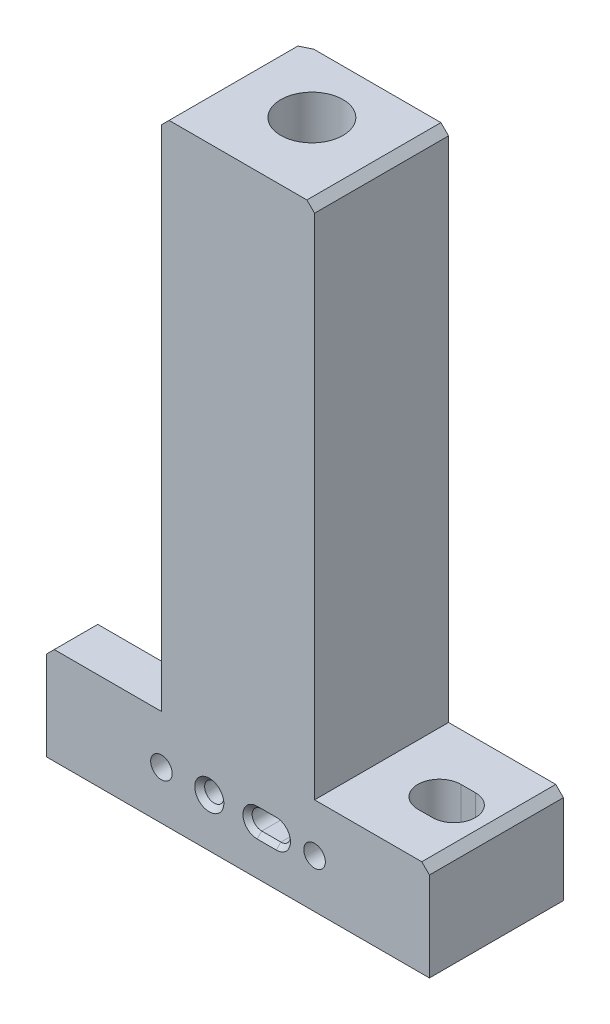
from build123d import *

# Parameters (mm, degrees)
EXTRUDE1_DEPTH                                   = 44.45
CHAMFER1_SIZE                                    = 2.54
CHAMFER2_SIZE                                    = 2.54
F_13_16_0_8125_DIAMETER_HOLE1_D                  = 20.6375
F_13_16_0_8125_DIAMETER_HOLE1_DEPTH              = 63.754
F_60_0_04_DIAMETER_HOLE1_REACH                   = 46.45
F_60_0_04_DIAMETER_HOLE1_BORE_R                  = 0.508
CBORE_FOR_1_4_SOCKET_HEAD_CAP_SCREW1_D           = 7.14248
CBORE_FOR_1_4_SOCKET_HEAD_CAP_SCREW1_CBORE_D     = 11.1125
CBORE_FOR_1_4_SOCKET_HEAD_CAP_SCREW1_CBORE_DEPTH = 15.748
F_1_4_0_25_DIAMETER_HOLE2_D                      = 6.36778
F_1_4_0_25_DIAMETER_HOLE2_DEPTH                  = 12.7
F_1_4_0_25_DIAMETER_HOLE2_CSINK_D                = 9.652
F_1_4_0_25_DIAMETER_HOLE2_CSINK_ANGLE            = 90
F_1_4_0_25_DIAMETER_HOLE2_TIP                    = 1.913074116
EXTRUDE4_DEPTH                                   = 12.7
F_1_2_20_TAPPED_HOLE3_D                          = 11.50874
F_1_2_20_TAPPED_HOLE3_DEPTH                      = 82.55
F_1_2_20_TAPPED_HOLE3_TIP                        = 3.322287069
EXTRUDE5_DEPTH                                   = 172.0690001
EXTRUDE5_DEPTH_BACK                              = 33.02
CHAMFER3_SIZE                                    = 1.524
EXTRUDE6_DEPTH                                   = 33.131
CUT_EXTRUDE1_DEPTH                               = 33.131


with BuildPart() as part:
    # Sketch1 → Extrude1 (new body)
    with BuildSketch(Plane.XY):
        Polygon((-63.5, 19.16234013), (-25.4, 19.16234013), (-25.4, 190.23134013), (0, 190.23134013), (0, -12.96865987), (-63.5, -12.96865987), align=None)
    extrude1 = extrude(amount=EXTRUDE1_DEPTH)

    # Mirror2: Extrude1 across plane
    add(extrude1.mirror(Plane(origin=(0, -12.96865987, 44.45), x_dir=(0, 0, 1), z_dir=(-1, 0, 0))))

    # Chamfer1
    chamfer1_edges = [part.edges().sort_by_distance(p)[0] for p in [
        (63.5, 19.16234013, 22.225),
        (25.4, 190.23134013, 22.225),
    ]]
    chamfer(chamfer1_edges, length=CHAMFER1_SIZE)

    # Chamfer2
    chamfer2_edges = [part.edges().sort_by_distance(p)[0] for p in [
        (-63.5, 19.16234013, 22.225),
        (-25.4, 190.23134013, 22.225),
    ]]
    chamfer(chamfer2_edges, length=CHAMFER2_SIZE)

    # 13/16 (0.8125) Diameter Hole1
    with Locations(Plane(origin=(0, 190.23134013, 19.939), x_dir=(0, 0, 1), z_dir=(0, 1, 0))):
        with Locations((0, 0)):
            Hole(F_13_16_0_8125_DIAMETER_HOLE1_D / 2, depth=F_13_16_0_8125_DIAMETER_HOLE1_DEPTH)

    # #60 (0.04) Diameter Hole1 bore → #60 (0.04) Diameter Hole1 (cut, up to next)
    with BuildSketch(Plane(origin=(0, 0, 0), x_dir=(-1, 0, 0), z_dir=(0, 0, -1)), mode=Mode.PRIVATE) as f_60_0_04_diameter_hole1_sk1:
        with Locations((0, 129.27134013)):
            Circle(F_60_0_04_DIAMETER_HOLE1_BORE_R)
    f_60_0_04_diameter_hole1_tool1 = extrude(f_60_0_04_diameter_hole1_sk1.sketch, amount=-F_60_0_04_DIAMETER_HOLE1_REACH, mode=Mode.PRIVATE) & part.part
    add(f_60_0_04_diameter_hole1_tool1.solids().sort_by_distance((0, 129.27134, 0))[0], mode=Mode.SUBTRACT)

    # CBORE for 1/4 Socket Head Cap Screw1 (through all)
    with Locations(Plane(origin=(25.4, 3.09684013, 0), x_dir=(-1, 0, 0), z_dir=(0, 0, -1))):
        with Locations((0, 0), (50.8, 0)):
            CounterBoreHole(CBORE_FOR_1_4_SOCKET_HEAD_CAP_SCREW1_D / 2, CBORE_FOR_1_4_SOCKET_HEAD_CAP_SCREW1_CBORE_D / 2, CBORE_FOR_1_4_SOCKET_HEAD_CAP_SCREW1_CBORE_DEPTH)

    # 1/4 (0.25) Diameter Hole2
    with Locations(Plane.XY.offset(44.45)):
        with Locations((-9.525, 3.09684013)):
            CounterSinkHole(F_1_4_0_25_DIAMETER_HOLE2_D / 2, F_1_4_0_25_DIAMETER_HOLE2_CSINK_D / 2, depth=F_1_4_0_25_DIAMETER_HOLE2_DEPTH, counter_sink_angle=F_1_4_0_25_DIAMETER_HOLE2_CSINK_ANGLE)
            with Locations((0, 0, -(F_1_4_0_25_DIAMETER_HOLE2_DEPTH + F_1_4_0_25_DIAMETER_HOLE2_TIP / 2))):  # 118° drill point
                Cone(0, F_1_4_0_25_DIAMETER_HOLE2_D / 2, F_1_4_0_25_DIAMETER_HOLE2_TIP, mode=Mode.SUBTRACT)

    # Sketch22 → Extrude4 (cut)
    with BuildSketch(Plane.XY.offset(44.45)):
        with BuildLine():
            Line((12.7, -0.08704987), (6.35, -0.08704987))
            ThreePointArc((6.35, -0.08704987), (3.16611, 3.09684013), (6.35, 6.28073013))
            Line((6.35, 6.28073013), (12.7, 6.28073013))
            ThreePointArc((12.7, 6.28073013), (15.88389, 3.09684013), (12.7, -0.08704987))
        make_face()
    extrude(amount=-EXTRUDE4_DEPTH, mode=Mode.SUBTRACT)

    # 1/2-20 Tapped Hole3
    with Locations(Plane(origin=(0, 126.47734013, 0), x_dir=(-1, 0, 0), z_dir=(0, 1, 0))):
        with Locations((0, 19.939)):
            Hole(F_1_2_20_TAPPED_HOLE3_D / 2, depth=F_1_2_20_TAPPED_HOLE3_DEPTH)
            with Locations((0, 0, -(F_1_2_20_TAPPED_HOLE3_DEPTH + F_1_2_20_TAPPED_HOLE3_TIP / 2))):  # 120° drill point
                Cone(0, F_1_2_20_TAPPED_HOLE3_D / 2, F_1_2_20_TAPPED_HOLE3_TIP, mode=Mode.SUBTRACT)

    # Sketch27 → Extrude5 (cut, two sides)
    with BuildSketch(Plane(origin=(0, 19.16234013, 0), x_dir=(1, 0, 0), z_dir=(0, 1, 0))) as extrude5_sk:
        Polygon((-19.338095495, 0), (-63.5, -21.5392), (-63.5, 0), align=None)
    extrude(amount=EXTRUDE5_DEPTH, mode=Mode.SUBTRACT)
    extrude(extrude5_sk.sketch, amount=-EXTRUDE5_DEPTH_BACK, mode=Mode.SUBTRACT)

    # Chamfer3
    chamfer3_edges = [part.edges().sort_by_distance(p)[0] for p in [
        (15.88389, 3.09684013, 44.45),
        (9.525, 6.28073013, 44.45),
        (3.16611, 3.09684013, 44.45),
        (9.525, -0.08704987, 44.45),
    ]]
    chamfer(chamfer3_edges, length=CHAMFER3_SIZE)

    # Sketch28 → Extrude6 (cut, through all)
    with BuildSketch(Plane(origin=(0, 19.16234013, 0), x_dir=(1, 0, 0), z_dir=(0, 1, 0))):
        with BuildLine():
            Line((45.212, -15.7226), (50.038, -15.7226))
            ThreePointArc((50.038, -15.7226), (57.1754, -22.86), (50.038, -29.9974))
            Line((50.038, -29.9974), (45.212, -29.9974))
            ThreePointArc((45.212, -29.9974), (38.0746, -22.86), (45.212, -15.7226))
        make_face()
        with BuildLine():
            Line((-38.227, -29.9974), (-63.627, -29.9974))
            ThreePointArc((-63.627, -29.9974), (-70.7644, -22.86), (-63.627, -15.7226))
            Line((-63.627, -15.7226), (-38.227, -15.7226))
            ThreePointArc((-38.227, -15.7226), (-31.0896, -22.86), (-38.227, -29.9974))
        make_face()
    extrude(amount=-EXTRUDE6_DEPTH, mode=Mode.SUBTRACT)

    # Sketch29 → Cut-Extrude1 (cut, through all)
    with BuildSketch(Plane(origin=(0, 19.16234013, 0), x_dir=(1, 0, 0), z_dir=(0, 1, 0))):
        Polygon((-51.574202675, -15.7226), (-50.050202675, -14.979295535), (-50.050202675, -15.7226), align=None)
    extrude(amount=-CUT_EXTRUDE1_DEPTH, mode=Mode.SUBTRACT)


solid = part.part
